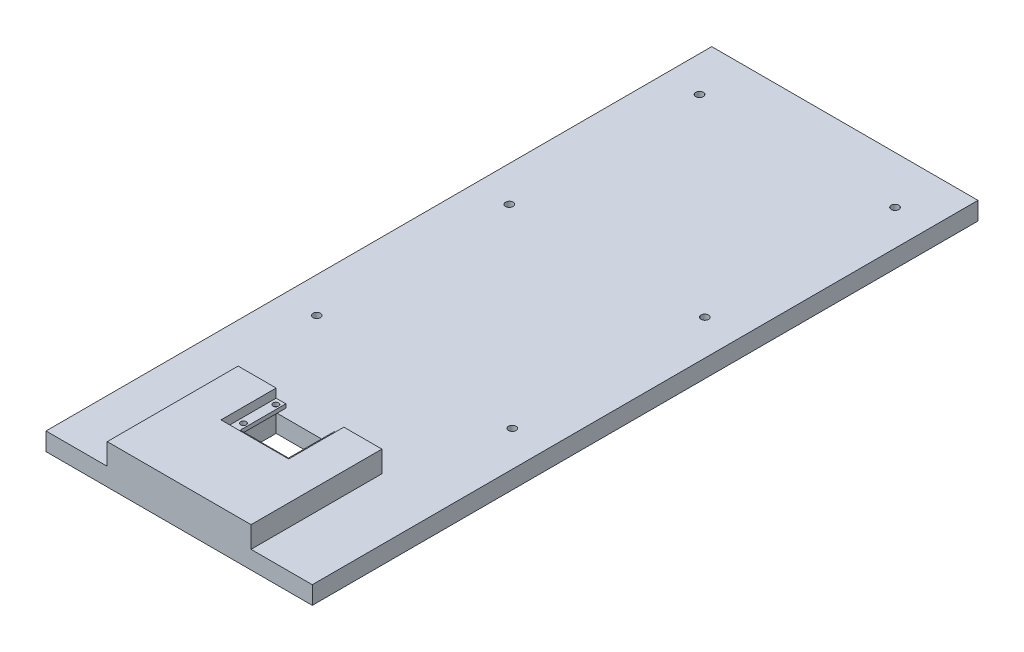
from build123d import *

# Parameters (mm, degrees)
SKETCH2_R            = 1.5
SKETCH2_W            = 25.4
SKETCH2_H            = 46
BOSS_EXTRUDE1_DEPTH  = 2
BOSS_EXTRUDE3_DEPTH  = 4.62
SKETCH5_5_R          = 1.5
CUT_EXTRUDE3_DEPTH   = 10
BOSS_EXTRUDE4_DEPTH  = 4.62
SKETCH8_W            = 140
SKETCH8_H            = 350
SKETCH8_W_2          = 35.6
SKETCH8_H_2          = 30
BOSS_EXTRUDE10_DEPTH = 4.63
SKETCH9_W            = 140
SKETCH9_H            = 350
SKETCH9_W_2          = 35.6
SKETCH9_H_2          = 30
BOSS_EXTRUDE11_DEPTH = 4.8
SKETCH10_R           = 2
CUT_EXTRUDE4_DEPTH   = 10.43


with BuildPart() as part:
    # Sketch2 → Boss-Extrude1 (new body)
    with BuildSketch(Plane(origin=(0, 0, 0), x_dir=(1, 0, 0), z_dir=(0, 1, 0))):
        Polygon((37.8, -65.8), (37.8, 64.2), (9.15, 64.2), (-37.8, 64.2), (-37.8, -65.8), align=None)
        with Locations((-8.5, -23.3)):
            Circle(SKETCH2_R, mode=Mode.SUBTRACT)
        with Locations((-15, -17)):
            Circle(SKETCH2_R, mode=Mode.SUBTRACT)
        with Locations((-15, 0)):
            Circle(SKETCH2_R, mode=Mode.SUBTRACT)
        with Locations((8.5, -23.3)):
            Circle(SKETCH2_R, mode=Mode.SUBTRACT)
        with Locations((15, -17)):
            Circle(SKETCH2_R, mode=Mode.SUBTRACT)
        with Locations((15, 0)):
            Circle(SKETCH2_R, mode=Mode.SUBTRACT)
        with Locations((-15, 17)):
            Circle(SKETCH2_R, mode=Mode.SUBTRACT)
        with Locations((0, 2)):
            Rectangle(SKETCH2_W, SKETCH2_H, mode=Mode.SUBTRACT)
        with Locations((15, 17)):
            Circle(SKETCH2_R, mode=Mode.SUBTRACT)
    extrude(amount=BOSS_EXTRUDE1_DEPTH)

    # Sketch5 → Boss-Extrude3 (add)
    with BuildSketch(Plane.XZ):
        Polygon((37.8, 30.8), (37.8, 65.8), (-37.8, 65.8), (-37.8, 30.8), (-37.8, -3), (-17.8, -3), (-17.8, 27), (17.8, 27), (17.8, -3), (37.8, -3), align=None)
    extrude(amount=BOSS_EXTRUDE3_DEPTH)

    # Sketch5_5 → Cut-Extrude3 (cut)
    with BuildSketch(Plane.XZ):
        Polygon((37.8, -3), (12.7, -3), (12.7, -25), (-12.7, -25), (-12.7, -3), (-37.8, -3), (-37.8, -64.2), (37.8, -64.2), align=None)
        with Locations((15, -17)):
            Circle(SKETCH5_5_R, mode=Mode.SUBTRACT)
        with Locations((-15, -17)):
            Circle(SKETCH5_5_R, mode=Mode.SUBTRACT)
    extrude(amount=-CUT_EXTRUDE3_DEPTH, mode=Mode.SUBTRACT)

    # Sketch6 → Boss-Extrude4 (add)
    with BuildSketch(Plane(origin=(0, 2, 0), x_dir=(1, 0, 0), z_dir=(0, 1, 0))):
        Polygon((-17.8, -25.996410493), (-17.8, 3), (-37.8, 3), (-37.8, -65.8), (0, -65.8), (37.8, -65.8), (37.8, 3), (17.8, 3), (17.8, -25.996410493), align=None)
    extrude(amount=BOSS_EXTRUDE4_DEPTH)

    # Sketch8 → Boss-Extrude10 (add)
    with BuildSketch(Plane.XZ.offset(4.62)):
        with Locations((0, -109.2)):
            Rectangle(SKETCH8_W, SKETCH8_H)
        with Locations((0, 12)):
            Rectangle(SKETCH8_W_2, SKETCH8_H_2, mode=Mode.SUBTRACT)
    extrude(amount=BOSS_EXTRUDE10_DEPTH)

    # Sketch9 → Boss-Extrude11 (add)
    with BuildSketch(Plane.XZ.offset(9.25)):
        with Locations((0, -109.2)):
            Rectangle(SKETCH9_W, SKETCH9_H)
        with Locations((0, 12)):
            Rectangle(SKETCH9_W_2, SKETCH9_H_2, mode=Mode.SUBTRACT)
    extrude(amount=BOSS_EXTRUDE11_DEPTH)

    # Sketch10 → Cut-Extrude4 (cut, through all)
    with BuildSketch(Plane(origin=(0, -4.62, 0), x_dir=(1, 0, 0), z_dir=(0, 1, 0))):
        with Locations((51.4, 57.95)):
            Circle(SKETCH10_R)
        with Locations((51.4, 159.2)):
            Circle(SKETCH10_R)
        with Locations((51.4, 259.2)):
            Circle(SKETCH10_R)
        with Locations((-51.4, 259.2)):
            Circle(SKETCH10_R)
        with Locations((-51.4, 57.95)):
            Circle(SKETCH10_R)
        with Locations((-51.4, 159.2)):
            Circle(SKETCH10_R)
    extrude(amount=-CUT_EXTRUDE4_DEPTH, mode=Mode.SUBTRACT)


solid = part.part
